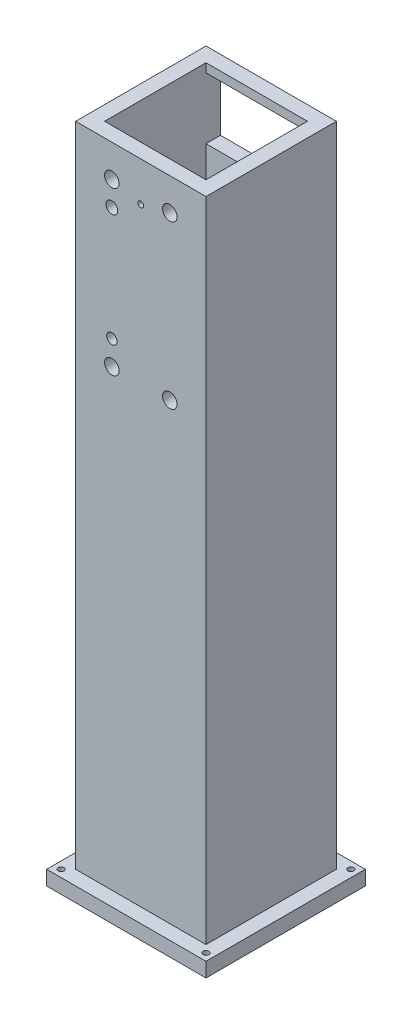
from build123d import *

# Parameters (mm, degrees)
CROQUIS1_W                 = 45
CROQUIS1_H                 = 45
SALIENTE_EXTRUIR1_DEPTH    = 300
CROQUIS4_W                 = 18
CROQUIS4_H                 = 34
CORTAR_EXTRUIR2_DEPTH      = 46
CROQUIS8_W                 = 35
CROQUIS8_H                 = 35
CORTAR_EXTRUIR3_DEPTH      = 301
CROQUIS9_W                 = 35
CROQUIS9_H                 = 21.174410022
CORTAR_EXTRUIR4_DEPTH      = 10
CROQUIS10_R                = 1
CORTAR_EXTRUIR5_DEPTH      = 10
CROQUIS11_W                = 45
CROQUIS11_H                = 26.387879272
CORTAR_EXTRUIR6_DEPTH      = 46
CROQUIS13_W                = 45
CROQUIS13_H                = 50
CORTAR_EXTRUIR7_DEPTH      = 23.5
CORTAR_EXTRUIR7_DEPTH_BACK = 23.5
CROQUIS14_W                = 55
CROQUIS14_H                = 55
SALIENTE_EXTRUIR2_DEPTH    = 5
CROQUIS16_R                = 1
CORTAR_EXTRUIR8_DEPTH      = 1
CORTAR_EXTRUIR8_DEPTH_BACK = 229.612120728
CROQUIS17_R                = 2.5
CROQUIS17_R_2              = 2.03
CROQUIS17_R_3              = 1.793308219
CORTAR_EXTRUIR9_DEPTH      = 6
CORTAR_EXTRUIR9_DEPTH_BACK = 51


with BuildPart() as part:
    # Croquis1 → Saliente-Extruir1 (new body)
    with BuildSketch(Plane(origin=(0, 0, 0), x_dir=(1, 0, 0), z_dir=(0, 1, 0))):
        Rectangle(CROQUIS1_W, CROQUIS1_H)
    extrude(amount=SALIENTE_EXTRUIR1_DEPTH)

    # Croquis4 → Cortar-Extruir2 (cut, through all)
    with BuildSketch(Plane.ZY.offset(22.5)):
        with Locations((13.5, 17)):
            Rectangle(CROQUIS4_W, CROQUIS4_H)
    extrude(amount=-CORTAR_EXTRUIR2_DEPTH, mode=Mode.SUBTRACT)

    # Croquis8 → Cortar-Extruir3 (cut, through all)
    with BuildSketch(Plane(origin=(0, 300, 0), x_dir=(1, 0, 0), z_dir=(0, 1, 0))):
        Rectangle(CROQUIS8_W, CROQUIS8_H)
    extrude(amount=-CORTAR_EXTRUIR3_DEPTH, mode=Mode.SUBTRACT)

    # Croquis9 → Cortar-Extruir4 (cut)
    with BuildSketch(Plane(origin=(0, 0, -22.5), x_dir=(-1, 0, 0), z_dir=(0, 0, -1))):
        with Locations((0, 260)):
            Rectangle(CROQUIS9_W, CROQUIS9_H)
    extrude(amount=-CORTAR_EXTRUIR4_DEPTH, mode=Mode.SUBTRACT)

    # Croquis10 → Cortar-Extruir5 (cut)
    with BuildSketch(Plane.XY.offset(22.5)):
        with Locations((0, 260)):
            Circle(CROQUIS10_R)
    extrude(amount=-CORTAR_EXTRUIR5_DEPTH, mode=Mode.SUBTRACT)

    # Croquis11 → Cortar-Extruir6 (cut, through all)
    with BuildSketch(Plane.XY.offset(22.5)):
        with Locations((0, 286.806060364)):
            Rectangle(CROQUIS11_W, CROQUIS11_H)
    extrude(amount=-CORTAR_EXTRUIR6_DEPTH, mode=Mode.SUBTRACT)

    # Croquis13 → Cortar-Extruir7 (cut, two sides)
    with BuildSketch(Plane(origin=(0, 0, 0), x_dir=(0, 0, -1), z_dir=(1, 0, 0))) as cortar_extruir7_sk:
        with Locations((0, 25)):
            Rectangle(CROQUIS13_W, CROQUIS13_H)
    extrude(amount=CORTAR_EXTRUIR7_DEPTH, mode=Mode.SUBTRACT)
    extrude(cortar_extruir7_sk.sketch, amount=-CORTAR_EXTRUIR7_DEPTH_BACK, mode=Mode.SUBTRACT)

    # Croquis14 → Saliente-Extruir2 (add)
    with BuildSketch(Plane.XZ.offset(-50)):
        Rectangle(CROQUIS14_W, CROQUIS14_H)
    extrude(amount=SALIENTE_EXTRUIR2_DEPTH)

    # Croquis16 → Cortar-Extruir8 (cut, two sides)
    with BuildSketch(Plane.XZ.offset(-45)) as cortar_extruir8_sk:
        with Locations((25, 25)):
            Circle(CROQUIS16_R)
        with Locations((-25, 25)):
            Circle(CROQUIS16_R)
        with Locations((-25, -25)):
            Circle(CROQUIS16_R)
        with Locations((25, -25)):
            Circle(CROQUIS16_R)
    extrude(amount=CORTAR_EXTRUIR8_DEPTH, mode=Mode.SUBTRACT)
    extrude(cortar_extruir8_sk.sketch, amount=-CORTAR_EXTRUIR8_DEPTH_BACK, mode=Mode.SUBTRACT)

    # Croquis17 → Cortar-Extruir9 (cut, two sides)
    with BuildSketch(Plane.XY.offset(22.5)) as cortar_extruir9_sk:
        with Locations((-10, 262.50260741)):
            Circle(CROQUIS17_R)
        with Locations((-10, 254.10260741)):
            Circle(CROQUIS17_R_2)
        with Locations((-10, 214.90260741)):
            Circle(CROQUIS17_R_3)
        with Locations((-10, 206.50260741)):
            Circle(CROQUIS17_R)
        with Locations((10, 262.50260741)):
            Circle(CROQUIS17_R)
        with Locations((10, 206.50260741)):
            Circle(CROQUIS17_R)
    extrude(amount=CORTAR_EXTRUIR9_DEPTH, mode=Mode.SUBTRACT)
    extrude(cortar_extruir9_sk.sketch, amount=-CORTAR_EXTRUIR9_DEPTH_BACK, mode=Mode.SUBTRACT)


solid = part.part
